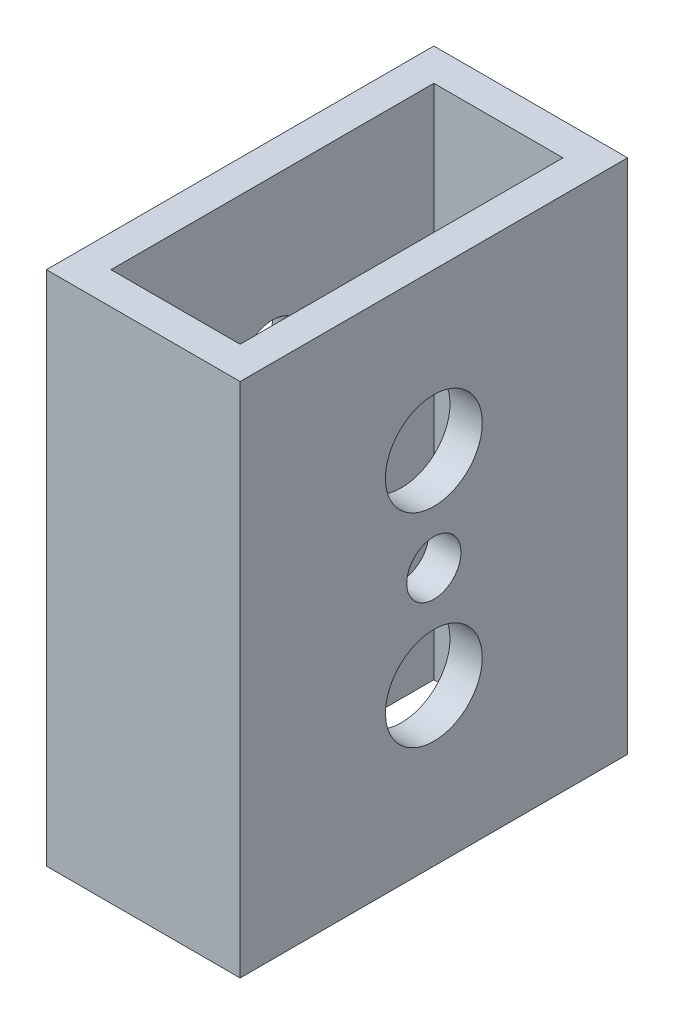
from build123d import *

# Parameters (mm, degrees)
SKETCH1_W           = 19.05
SKETCH1_H           = 38.1
SKETCH1_W_2         = 12.7
SKETCH1_H_2         = 31.75
BOSS_EXTRUDE1_DEPTH = 50.8
SKETCH2_R           = 3.175
CUT_EXTRUDE1_DEPTH  = 20.05
CUT_EXTRUDE2_REACH  = 21.05
SKETCH3_R           = 4.7625
SKETCH4_R           = 2.667
CUT_EXTRUDE3_DEPTH  = 20.05
CUT_EXTRUDE4_REACH  = 21.05
SKETCH5_R           = 4.7625


with BuildPart() as part:
    # Sketch1 → Boss-Extrude1 (new body)
    with BuildSketch(Plane(origin=(0, 0, 0), x_dir=(1, 0, 0), z_dir=(0, 1, 0))):
        with Locations((9.525, 19.05)):
            Rectangle(SKETCH1_W, SKETCH1_H)
        with Locations((9.525, 19.05)):
            Rectangle(SKETCH1_W_2, SKETCH1_H_2, mode=Mode.SUBTRACT)
    extrude(amount=BOSS_EXTRUDE1_DEPTH)

    # Sketch2 → Cut-Extrude1 (cut, through all)
    with BuildSketch(Plane(origin=(19.05, 0, 0), x_dir=(0, 0, -1), z_dir=(1, 0, 0))):
        with Locations((19.05, 15.40002)):
            Circle(SKETCH2_R)
        with Locations((19.05, 35.39998)):
            Circle(SKETCH2_R)
    extrude(amount=-CUT_EXTRUDE1_DEPTH, mode=Mode.SUBTRACT)

    # Sketch3 → Cut-Extrude2 (cut, up to next)
    with BuildSketch(Plane(origin=(19.05, 0, 0), x_dir=(0, 0, -1), z_dir=(1, 0, 0)), mode=Mode.PRIVATE) as cut_extrude2_sk1:
        with Locations((19.05, 15.40002)):
            Circle(SKETCH3_R)
    cut_extrude2_tool1 = extrude(cut_extrude2_sk1.sketch, amount=-CUT_EXTRUDE2_REACH, mode=Mode.PRIVATE) & part.part
    add(cut_extrude2_tool1.solids().sort_by_distance((19.05, 15.40002, -19.05))[0], mode=Mode.SUBTRACT)
    # Sketch3 → Cut-Extrude2 (cut, up to next)
    with BuildSketch(Plane(origin=(19.05, 0, 0), x_dir=(0, 0, -1), z_dir=(1, 0, 0)), mode=Mode.PRIVATE) as cut_extrude2_sk2:
        with Locations((19.05, 35.39998)):
            Circle(SKETCH3_R)
    cut_extrude2_tool2 = extrude(cut_extrude2_sk2.sketch, amount=-CUT_EXTRUDE2_REACH, mode=Mode.PRIVATE) & part.part
    add(cut_extrude2_tool2.solids().sort_by_distance((19.05, 35.39998, -19.05))[0], mode=Mode.SUBTRACT)

    # Sketch4 → Cut-Extrude3 (cut, through all)
    with BuildSketch(Plane.ZY):
        with Locations((-19.05, 25.4)):
            Circle(SKETCH4_R)
    extrude(amount=-CUT_EXTRUDE3_DEPTH, mode=Mode.SUBTRACT)

    # Sketch5 → Cut-Extrude4 (cut, up to next)
    with BuildSketch(Plane.ZY, mode=Mode.PRIVATE) as cut_extrude4_sk1:
        with Locations((-19.05, 25.4)):
            Circle(SKETCH5_R)
    cut_extrude4_tool1 = extrude(cut_extrude4_sk1.sketch, amount=-CUT_EXTRUDE4_REACH, mode=Mode.PRIVATE) & part.part
    add(cut_extrude4_tool1.solids().sort_by_distance((0, 25.4, -19.05))[0], mode=Mode.SUBTRACT)


solid = part.part
